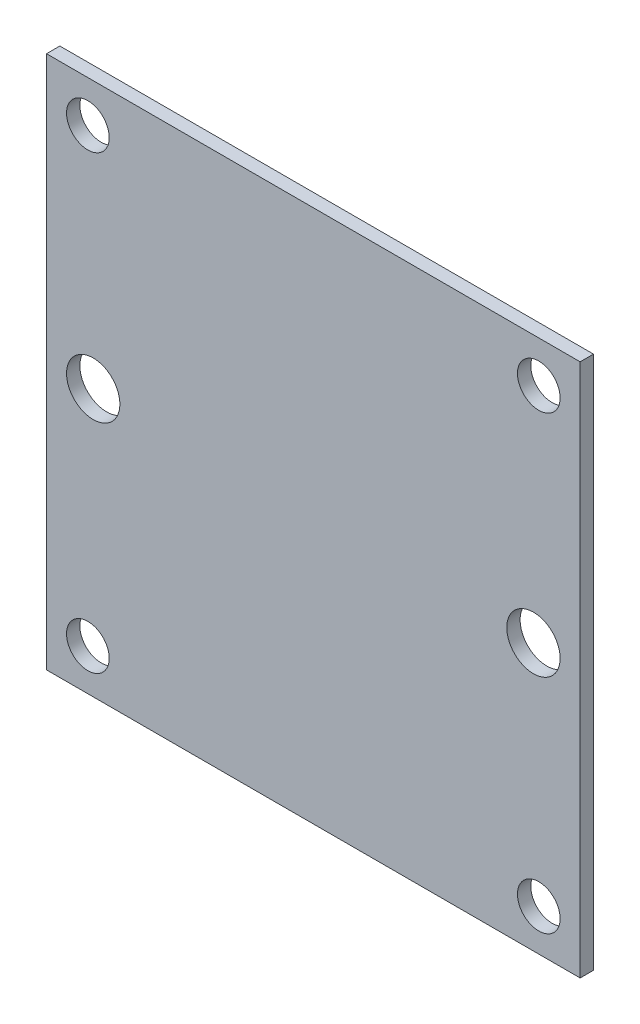
from build123d import *

# Parameters (mm, degrees)
SKETCH1_W           = 40
SKETCH1_H           = 40
BOSS_EXTRUDE1_DEPTH = 1
SKETCH2_R           = 1.6
SKETCH2_R_2         = 2
CUT_EXTRUDE1_DEPTH  = 10


with BuildPart() as part:
    # Sketch1 → Boss-Extrude1 (new body)
    with BuildSketch(Plane.XY):
        Rectangle(SKETCH1_W, SKETCH1_H)
    extrude(amount=BOSS_EXTRUDE1_DEPTH)

    # Sketch2 → Cut-Extrude1 (cut)
    with BuildSketch(Plane.XY.offset(1)):
        with Locations((-16.9, -16.9)):
            Circle(SKETCH2_R)
        with Locations((16.9, -16.9)):
            Circle(SKETCH2_R)
        with Locations((16.9, 16.9)):
            Circle(SKETCH2_R)
        with Locations((-16.9, 16.9)):
            Circle(SKETCH2_R)
        with Locations((16.5, 0)):
            Circle(SKETCH2_R_2)
        with Locations((-16.5, 0)):
            Circle(SKETCH2_R_2)
    extrude(amount=-CUT_EXTRUDE1_DEPTH, mode=Mode.SUBTRACT)


solid = part.part
